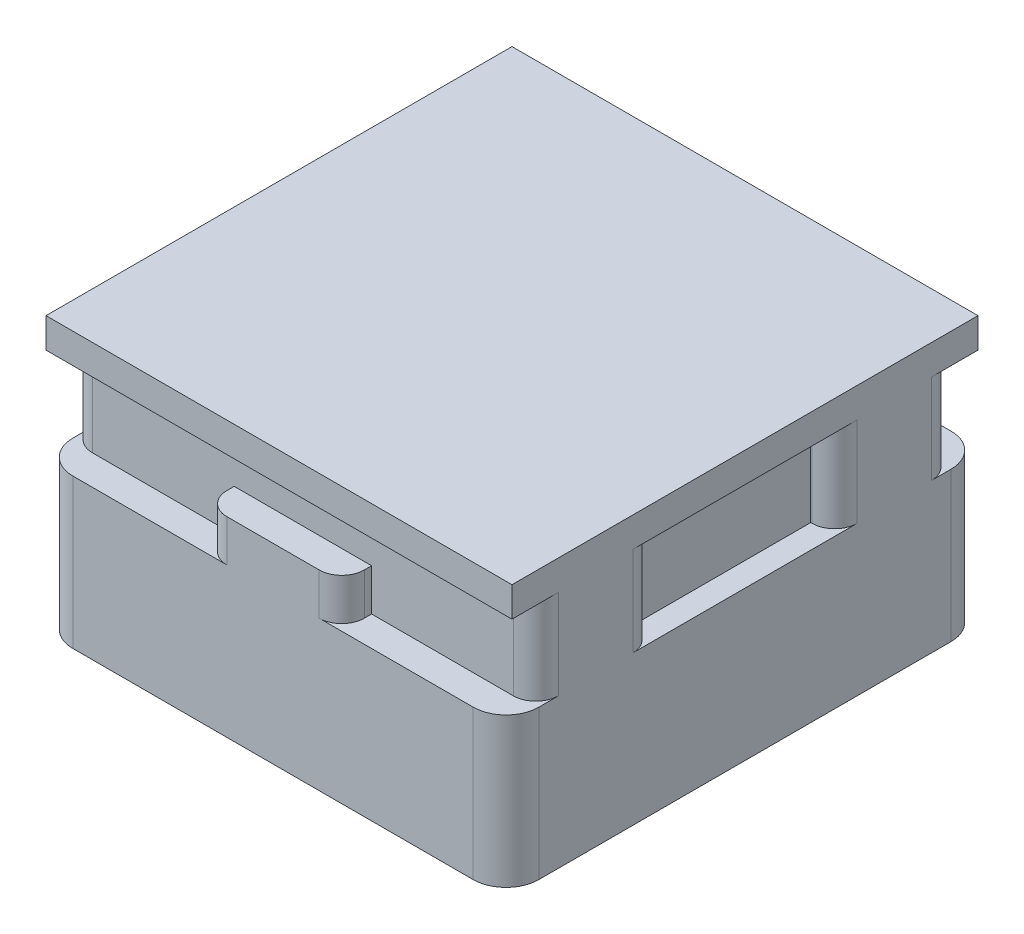
from build123d import *

# Parameters (mm, degrees)
SKETCH2_W           = 15.6
SKETCH2_H           = 15.6
BOSS_EXTRUDE2_DEPTH = 1
BOSS_EXTRUDE1_DEPTH = 3
SKETCH3_W           = 4.6
SKETCH3_H           = 1
BOSS_EXTRUDE3_DEPTH = 1.4
FILLET1_R           = 0.755
BOSS_EXTRUDE4_DEPTH = 5


with BuildPart() as part:
    # Sketch2 → Boss-Extrude2 (new body)
    with BuildSketch(Plane(origin=(0, 0, 0), x_dir=(1, 0, 0), z_dir=(0, 1, 0))):
        Rectangle(SKETCH2_W, SKETCH2_H)
    extrude(amount=BOSS_EXTRUDE2_DEPTH)

    # Cutout → Boss-Extrude1 (add)
    with BuildSketch(Plane(origin=(0, 0, 0), x_dir=(1, 0, 0), z_dir=(0, 1, 0))):
        Polygon((-7.8, 3), (-7, 3), (-7, -3), (-7.8, -3), (-7.8, -7), (7.8, -7), (7.8, -3), (7, -3), (7, 3), (7.8, 3), (7.8, 7), (-7.8, 7), align=None)
    extrude(amount=-BOSS_EXTRUDE1_DEPTH)

    # Sketch3 → Boss-Extrude3 (add)
    with BuildSketch(Plane(origin=(0, -1.6, 0), x_dir=(-1, 0, 0), z_dir=(0, 1, 0))):
        with Locations((0, 7.5)):
            Rectangle(SKETCH3_W, SKETCH3_H)
    boss_extrude3 = extrude(amount=-BOSS_EXTRUDE3_DEPTH)

    # Mirror1: Boss-Extrude3 across plane
    add(boss_extrude3.mirror(Plane.XY))

    # Fillet1
    fillet1_edges = [part.edges().sort_by_distance(p)[0] for p in [
        (7.8, -1.5, 7),
        (7.8, -1.5, 3),
        (7.8, -1.5, -3),
        (7.8, -1.5, -7),
        (2.3, -2.3, -8),
        (-2.3, -2.3, -8),
        (-7.8, -1.5, -3),
        (-7.8, -1.5, -7),
        (2.3, -2.3, 8),
        (-2.3, -2.3, 8),
        (-7.8, -1.5, 7),
        (-7.8, -1.5, 3),
    ]]
    fillet(fillet1_edges, radius=FILLET1_R)

    # Sketch4 → Boss-Extrude4 (add)
    with BuildSketch(Plane.XZ.offset(3)):
        with BuildLine():
            Line((-6.7, -8), (6.7, -8))
            ThreePointArc((6.7, -8), (7.477817459, -7.677817459), (7.8, -6.9))
            Line((7.8, -6.9), (7.8, 6.9))
            ThreePointArc((7.8, 6.9), (7.477817459, 7.677817459), (6.7, 8))
            Line((6.7, 8), (-6.7, 8))
            ThreePointArc((-6.7, 8), (-7.477817459, 7.677817459), (-7.8, 6.9))
            Line((-7.8, 6.9), (-7.8, -6.9))
            ThreePointArc((-7.8, -6.9), (-7.477817459, -7.677817459), (-6.7, -8))
        make_face()
    extrude(amount=BOSS_EXTRUDE4_DEPTH)


solid = part.part
